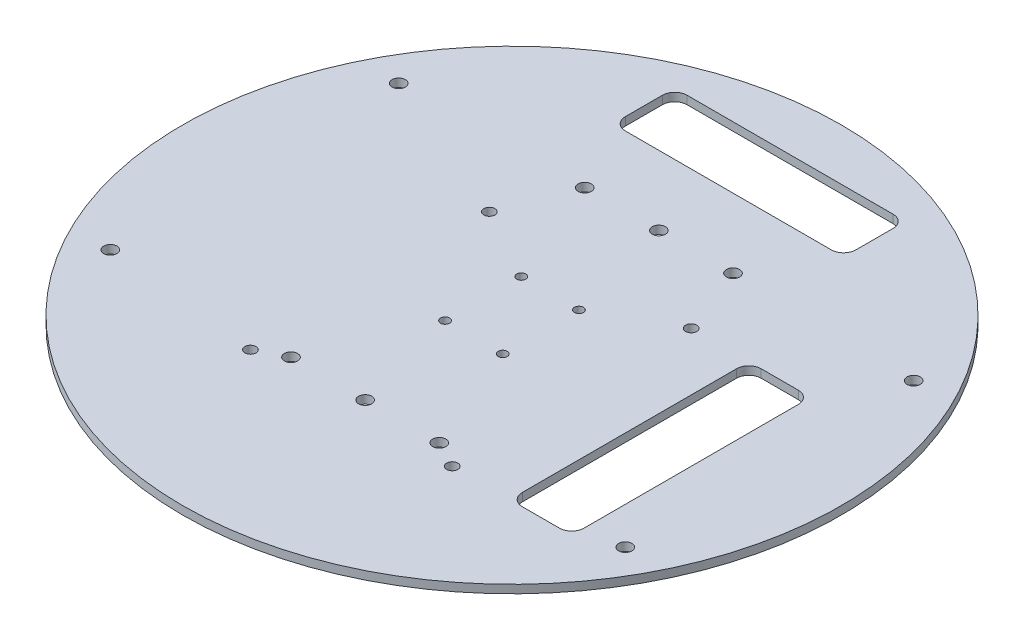
from build123d import *

# Parameters (mm, degrees)
SKETCH_1_R             = 80
EXTRUDE_1_DEPTH        = 2
SKETCH_2_R             = 1.6
CUT_EXTRUDE_445_DEPTH  = 2
SKETCH_3_R             = 1.35
SKETCH_3_W             = 56
SKETCH_3_H             = 15
SKETCH_3_W_2           = 15
SKETCH_3_H_2           = 58
CUT_EXTRUDE_949_DEPTH  = 2
SKETCH_4_R             = 1.6
CUT_EXTRUDE_1375_DEPTH = 2
SKETCH_5_R             = 1.1
CUT_EXTRUDE_1819_DEPTH = 2
FILLET_2_R             = 3


with BuildPart() as part:
    # 草图1 → 凸台-拉伸1 (new body)
    with BuildSketch(Plane(origin=(0, 0, 0), x_dir=(1, 0, 0), z_dir=(0, 1, 0))):
        Circle(SKETCH_1_R)
    extrude(amount=EXTRUDE_1_DEPTH)

    # 草图2 → Cut-Extrude 445 (cut)
    with BuildSketch(Plane(origin=(0, 2, 0), x_dir=(1, 0, 0), z_dir=(0, 1, 0))):
        with Locations((-62.5, 35)):
            Circle(SKETCH_2_R)
        with Locations((-62.5, -35)):
            Circle(SKETCH_2_R)
        with Locations((62.5, -35)):
            Circle(SKETCH_2_R)
        with Locations((62.5, 35)):
            Circle(SKETCH_2_R)
    extrude(amount=-CUT_EXTRUDE_445_DEPTH, mode=Mode.SUBTRACT)

    # 草图3 → Cut-Extrude 949 (cut)
    with BuildSketch(Plane(origin=(0, 2, 0), x_dir=(1, 0, 0), z_dir=(0, 1, 0))):
        with Locations((-24.5, 19)):
            Circle(SKETCH_3_R)
        with Locations((-24.5, -39)):
            Circle(SKETCH_3_R)
        with Locations((24.5, -39)):
            Circle(SKETCH_3_R)
        with Locations((24.5, 19)):
            Circle(SKETCH_3_R)
        with Locations((0, 60)):
            Rectangle(SKETCH_3_W, SKETCH_3_H)
        with Locations((46, -10)):
            Rectangle(SKETCH_3_W_2, SKETCH_3_H_2)
    extrude(amount=-CUT_EXTRUDE_949_DEPTH, mode=Mode.SUBTRACT)

    # 草图4 → Cut-Extrude 1375 (cut)
    with BuildSketch(Plane(origin=(0, 2, 0), x_dir=(1, 0, 0), z_dir=(0, 1, 0))):
        with Locations((-18, 35.65)):
            Circle(SKETCH_4_R)
        with Locations((0, 35.65)):
            Circle(SKETCH_4_R)
        with Locations((18, 35.65)):
            Circle(SKETCH_4_R)
        with Locations((18, -35.65)):
            Circle(SKETCH_4_R)
        with Locations((0, -35.65)):
            Circle(SKETCH_4_R)
        with Locations((-18, -35.65)):
            Circle(SKETCH_4_R)
    extrude(amount=-CUT_EXTRUDE_1375_DEPTH, mode=Mode.SUBTRACT)

    # 草图5 → Cut-Extrude 1819 (cut)
    with BuildSketch(Plane(origin=(0, 2, 0), x_dir=(1, 0, 0), z_dir=(0, 1, 0))):
        with Locations((-7, 9.25)):
            Circle(SKETCH_5_R)
        with Locations((7, 9.25)):
            Circle(SKETCH_5_R)
        with Locations((7, -9.25)):
            Circle(SKETCH_5_R)
        with Locations((-7, -9.25)):
            Circle(SKETCH_5_R)
    extrude(amount=-CUT_EXTRUDE_1819_DEPTH, mode=Mode.SUBTRACT)

    # 圆角2
    fillet_2_edges = [part.edges().sort_by_distance(p)[0] for p in [
        (38.5, 1, 39),
        (38.5, 1, -19),
        (53.5, 1, -19),
        (53.5, 1, 39),
        (-28, 1, -52.5),
        (-28, 1, -67.5),
        (28, 1, -67.5),
        (28, 1, -52.5),
    ]]
    fillet(fillet_2_edges, radius=FILLET_2_R)


solid = part.part
